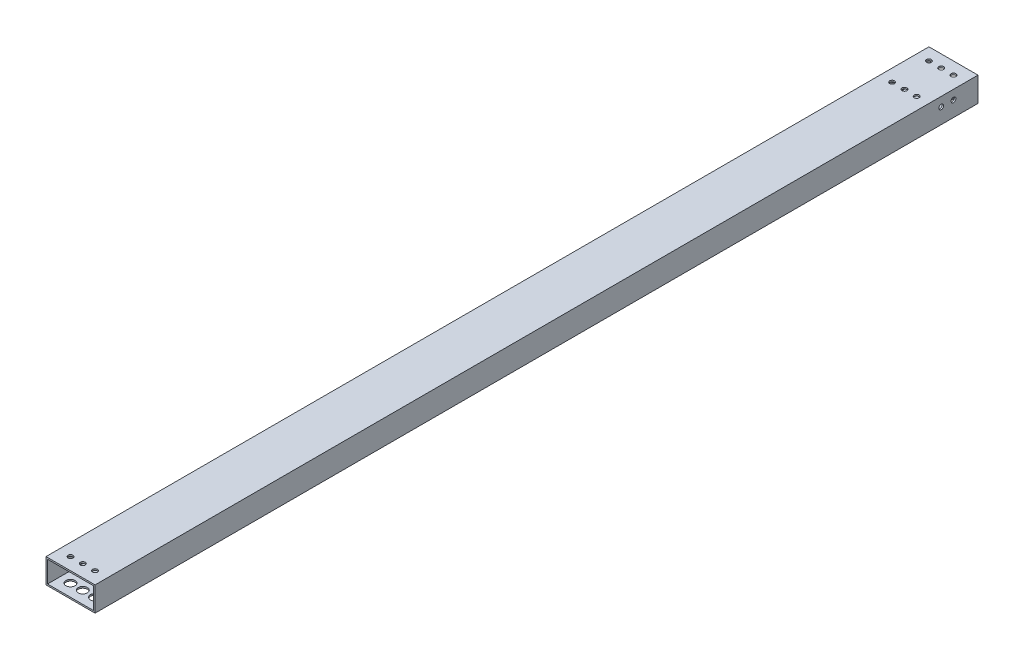
from build123d import *

# Parameters (mm, degrees)
SKETCH1_W           = 50.8
SKETCH1_H           = 25.4
SKETCH1_W_2         = 47.625
SKETCH1_H_2         = 22.225
BOSS_EXTRUDE1_DEPTH = 457.2
SKETCH3_R           = 2.5527
CUT_EXTRUDE2_DEPTH  = 1.5875
SKETCH4_R           = 4.7625
SKETCH4_R_2         = 2.5527
CUT_EXTRUDE4_DEPTH  = 1.5875
SKETCH7_R           = 2.4892
CUT_EXTRUDE5_DEPTH  = 461.188841673
SKETCH10_R          = 2.5527
CUT_EXTRUDE6_DEPTH  = 459.608940166


with BuildPart() as part:
    # Sketch1 → Boss-Extrude1 (new, symmetric)
    with BuildSketch(Plane.XY):
        Rectangle(SKETCH1_W, SKETCH1_H)
        Rectangle(SKETCH1_W_2, SKETCH1_H_2, mode=Mode.SUBTRACT)
    extrude(amount=BOSS_EXTRUDE1_DEPTH, both=True)

    # Sketch3 → Cut-Extrude2 (cut)
    with BuildSketch(Plane(origin=(0, 12.7, 0), x_dir=(1, 0, 0), z_dir=(0, 1, 0))):
        with Locations(Location((0, -444.5, 0), (0, 0, 270))):
            Circle(SKETCH3_R)
        with Locations(Location((12.7, -444.5, 0), (0, 0, 270))):
            Circle(SKETCH3_R)
        with Locations(Location((-12.7, -444.5, 0), (0, 0, 270))):
            Circle(SKETCH3_R)
        with Locations((12.7, 444.5)):
            Circle(SKETCH3_R)
        with Locations((0, 444.5)):
            Circle(SKETCH3_R)
        with Locations((-12.7, 444.5)):
            Circle(SKETCH3_R)
    extrude(amount=-CUT_EXTRUDE2_DEPTH, mode=Mode.SUBTRACT)

    # Sketch4 → Cut-Extrude4 (cut)
    with BuildSketch(Plane.XZ.offset(12.7)):
        with Locations(Location((-12.7, 444.5, 0), (0, 0, 270))):
            Circle(SKETCH4_R)
        with Locations(Location((-12.7, 444.5, 0), (0, 0, 90))):
            Circle(SKETCH4_R_2, mode=Mode.SUBTRACT)
        with Locations(Location((0, 444.5, 0), (0, 0, 270))):
            Circle(SKETCH4_R)
        with Locations(Location((0, 444.5, 0), (0, 0, 90))):
            Circle(SKETCH4_R_2, mode=Mode.SUBTRACT)
        with Locations(Location((0, 444.5, 0), (0, 0, 90))):
            Circle(SKETCH4_R_2)
        with Locations(Location((-12.7, 444.5, 0), (0, 0, 90))):
            Circle(SKETCH4_R_2)
        with Locations(Location((12.7, 444.5, 0), (0, 0, 270))):
            Circle(SKETCH4_R)
        with Locations(Location((12.7, 444.5, 0), (0, 0, 90))):
            Circle(SKETCH4_R_2, mode=Mode.SUBTRACT)
        with Locations(Location((12.7, 444.5, 0), (0, 0, 90))):
            Circle(SKETCH4_R_2)
        with Locations(Location((12.7, -444.5, 0), (0, 0, 270))):
            Circle(SKETCH4_R)
        with Locations((12.7, -444.5)):
            Circle(SKETCH4_R_2, mode=Mode.SUBTRACT)
        with Locations((12.7, -444.5)):
            Circle(SKETCH4_R_2)
        with Locations(Location((0, -444.5, 0), (0, 0, 270))):
            Circle(SKETCH4_R)
        with Locations((0, -444.5)):
            Circle(SKETCH4_R_2, mode=Mode.SUBTRACT)
        with Locations((0, -444.5)):
            Circle(SKETCH4_R_2)
        with Locations(Location((-12.7, -444.5, 0), (0, 0, 270))):
            Circle(SKETCH4_R)
        with Locations((-12.7, -444.5)):
            Circle(SKETCH4_R_2, mode=Mode.SUBTRACT)
        with Locations((-12.7, -444.5)):
            Circle(SKETCH4_R_2)
    extrude(amount=-CUT_EXTRUDE4_DEPTH, mode=Mode.SUBTRACT)

    # Sketch7 → Cut-Extrude5 (cut, through all)
    with BuildSketch(Plane(origin=(25.4, 0, 0), x_dir=(0, 0, -1), z_dir=(1, 0, 0))):
        with Locations((419.1, 3.175)):
            Circle(SKETCH7_R)
        with Locations((431.8, 3.175)):
            Circle(SKETCH7_R)
    extrude(amount=-CUT_EXTRUDE5_DEPTH, mode=Mode.SUBTRACT)

    # Sketch10 → Cut-Extrude6 (cut, through all)
    with BuildSketch(Plane(origin=(0, 12.7, 0), x_dir=(1, 0, 0), z_dir=(0, 1, 0))):
        with Locations(Location((-12.7, 406.4, 0), (0, 0, 270))):
            Circle(SKETCH10_R)
        with Locations(Location((0, 406.4, 0), (0, 0, 270))):
            Circle(SKETCH10_R)
        with Locations(Location((12.7, 406.4, 0), (0, 0, 270))):
            Circle(SKETCH10_R)
    extrude(amount=-CUT_EXTRUDE6_DEPTH, mode=Mode.SUBTRACT)


solid = part.part
